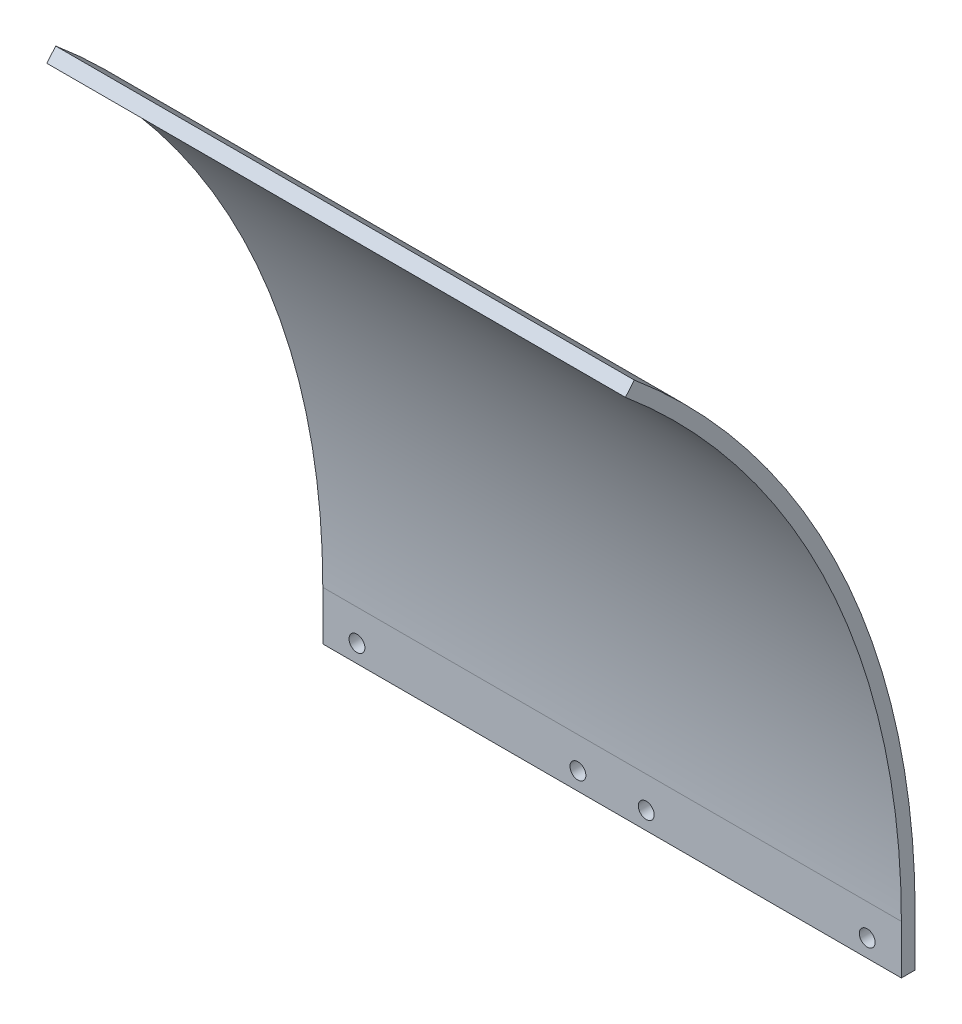
from build123d import *

# Parameters (mm, degrees)
BOSS_EXTRUDE1_DEPTH = 133.35
CUT_EXTRUDE1_DEPTH  = 134.35
SKETCH3_W           = 133.35
SKETCH3_H           = 3.175
BOSS_EXTRUDE2_DEPTH = 11.303
SKETCH4_R           = 1.8288
CUT_EXTRUDE2_DEPTH  = 4.175


with BuildPart() as part:
    # Sketch1 → Boss-Extrude1 (new body)
    with BuildSketch(Plane(origin=(0, 0, 0), x_dir=(0, 0, -1), z_dir=(1, 0, 0))):
        with BuildLine():
            Line((0, 178.054), (0, 181.229))
            ThreePointArc((0, 181.229), (128.148254848, 128.148254848), (181.229, 0))
            Line((181.229, 0), (178.054, 0))
            ThreePointArc((178.054, 0), (125.903190817, 125.903190817), (0, 178.054))
        make_face()
    extrude(amount=BOSS_EXTRUDE1_DEPTH)

    # Sketch2 → Cut-Extrude1 (cut, through all)
    with BuildSketch(Plane(origin=(133.35, 0, 0), x_dir=(0, 0, -1), z_dir=(1, 0, 0))):
        with BuildLine():
            Line((114.450905055, 136.397277275), (116.491755716, 138.829468382))
            ThreePointArc((116.491755716, 138.829468382), (61.983968555, 170.299553972), (0, 181.229))
            Line((0, 181.229), (0, 178.054))
            ThreePointArc((0, 178.054), (60.8980546, 167.316029901), (114.450905055, 136.397277275))
        make_face()
    extrude(amount=-CUT_EXTRUDE1_DEPTH, mode=Mode.SUBTRACT)

    # Sketch3 → Boss-Extrude2 (add)
    with BuildSketch(Plane.XZ):
        with Locations((66.675, -179.6415)):
            Rectangle(SKETCH3_W, SKETCH3_H)
    extrude(amount=BOSS_EXTRUDE2_DEPTH)

    # Sketch4 → Cut-Extrude2 (cut, through all)
    with BuildSketch(Plane.XY.offset(-178.054)):
        with Locations((7.874, -7.239)):
            Circle(SKETCH4_R)
        with Locations((58.801, -7.239)):
            Circle(SKETCH4_R)
        with Locations((74.549, -7.239)):
            Circle(SKETCH4_R)
        with Locations((125.476, -7.239)):
            Circle(SKETCH4_R)
    extrude(amount=-CUT_EXTRUDE2_DEPTH, mode=Mode.SUBTRACT)


solid = part.part
